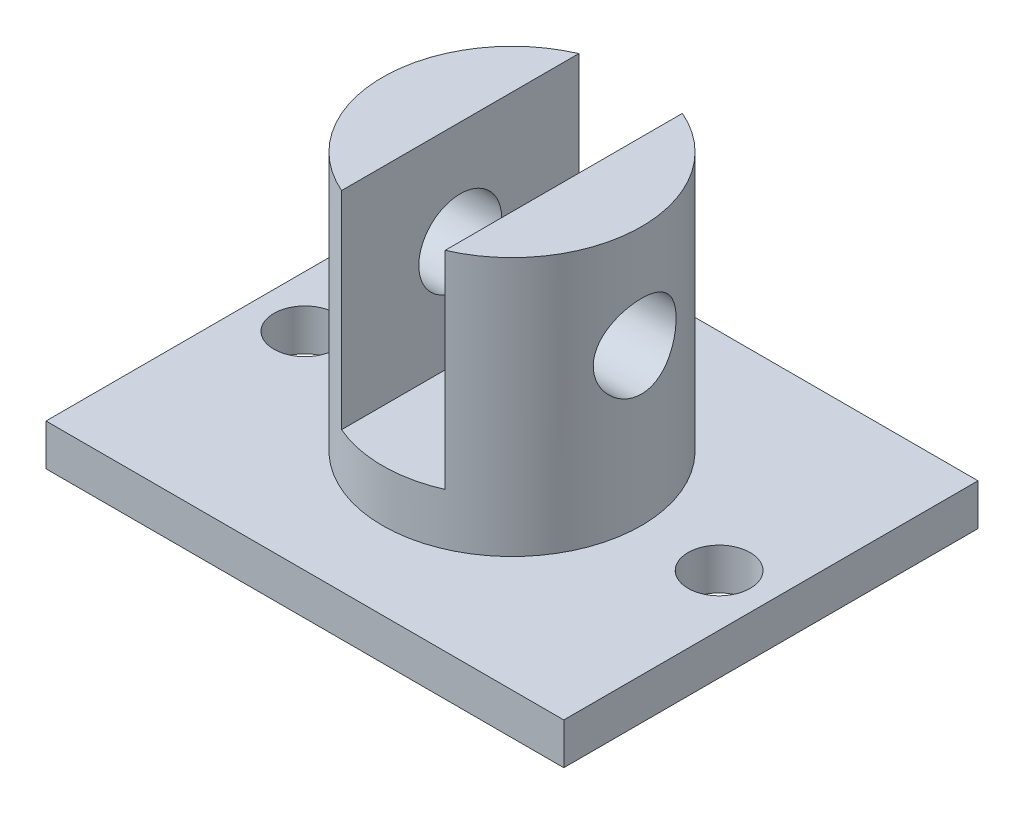
from build123d import *

# Parameters (mm, degrees)
SKETCH_1_W               = 50
SKETCH_1_H               = 40
EXTRUDE_1_DEPTH          = 4
SKETCH_2_R               = 12.5
EXTRUDE_2_DEPTH          = 25
SKETCH_3_W               = 10
SKETCH_3_H               = 20
CUT_EXTRUDE_1_DEPTH      = 20
SKETCH_4_R               = 4
CUT_EXTRUDE_2_DEPTH      = 26
CUT_EXTRUDE_2_DEPTH_BACK = 26
SKETCH_5_R               = 3
CUT_EXTRUDE_3_DEPTH      = 10


with BuildPart() as part:
    # 草图1 → 凸台-拉伸1 (new body)
    with BuildSketch(Plane(origin=(0, 0, 0), x_dir=(1, 0, 0), z_dir=(0, 1, 0))):
        Rectangle(SKETCH_1_W, SKETCH_1_H)
    extrude(amount=EXTRUDE_1_DEPTH)

    # 草图2 → 凸台-拉伸2 (add)
    with BuildSketch(Plane(origin=(0, 4, 0), x_dir=(1, 0, 0), z_dir=(0, 1, 0))):
        Circle(SKETCH_2_R)
    extrude(amount=EXTRUDE_2_DEPTH)

    # 草图3 → 切除-拉伸1 (cut, symmetric)
    with BuildSketch(Plane.XY):
        with Locations((0, 19)):
            Rectangle(SKETCH_3_W, SKETCH_3_H)
    extrude(amount=CUT_EXTRUDE_1_DEPTH, both=True, mode=Mode.SUBTRACT)

    # 草图4 → 切除-拉伸2 (cut, two sides)
    with BuildSketch(Plane(origin=(0, 0, 0), x_dir=(0, 0, -1), z_dir=(1, 0, 0))) as cut_extrude_2_sk:
        with Locations((0, 19)):
            Circle(SKETCH_4_R)
    extrude(amount=CUT_EXTRUDE_2_DEPTH, mode=Mode.SUBTRACT)
    extrude(cut_extrude_2_sk.sketch, amount=-CUT_EXTRUDE_2_DEPTH_BACK, mode=Mode.SUBTRACT)

    # 草图5 → 切除-拉伸3 (cut)
    with BuildSketch(Plane(origin=(0, 4, 0), x_dir=(1, 0, 0), z_dir=(0, 1, 0))):
        with Locations((-20, 0)):
            Circle(SKETCH_5_R)
        with Locations((20, 0)):
            Circle(SKETCH_5_R)
    extrude(amount=-CUT_EXTRUDE_3_DEPTH, mode=Mode.SUBTRACT)


solid = part.part
